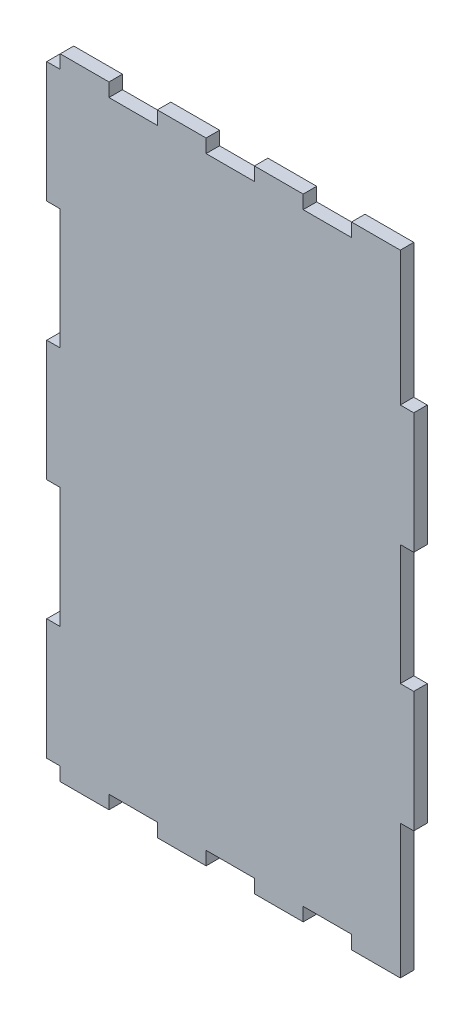
from build123d import *

# Parameters (mm, degrees)
SKETCH1_W           = 135.975
SKETCH1_H           = 241.325
SKETCH1_W_2         = 19.425
SKETCH1_H_2         = 5.4
SKETCH1_W_3         = 5.4
SKETCH1_H_3         = 48.265
BOSS_EXTRUDE1_DEPTH = 5.4
BOSS_EXTRUDE2_DEPTH = 5.4


with BuildPart() as part:
    # Sketch1 → Boss-Extrude1 (new body)
    with BuildSketch(Plane.XY):
        Rectangle(SKETCH1_W, SKETCH1_H)
        with Locations((58.275, 123.3625)):
            Rectangle(SKETCH1_W_2, SKETCH1_H_2)
        with Locations((19.425, 123.3625)):
            Rectangle(SKETCH1_W_2, SKETCH1_H_2)
        with Locations((-19.425, 123.3625)):
            Rectangle(SKETCH1_W_2, SKETCH1_H_2)
        with Locations((-70.6875, 96.53)):
            Rectangle(SKETCH1_W_3, SKETCH1_H_3)
        with Locations((-58.275, 123.3625)):
            Rectangle(SKETCH1_W_2, SKETCH1_H_2)
        with Locations((70.6875, 48.265)):
            Rectangle(SKETCH1_W_3, SKETCH1_H_3)
        with Locations((-70.6875, 0)):
            Rectangle(SKETCH1_W_3, SKETCH1_H_3)
        with Locations((70.6875, -48.265)):
            Rectangle(SKETCH1_W_3, SKETCH1_H_3)
        with Locations((-70.6875, -96.53)):
            Rectangle(SKETCH1_W_3, SKETCH1_H_3)
        with Locations((-58.275, -123.3625)):
            Rectangle(SKETCH1_W_2, SKETCH1_H_2)
        with Locations((-19.425, -123.3625)):
            Rectangle(SKETCH1_W_2, SKETCH1_H_2)
        with Locations((19.425, -123.3625)):
            Rectangle(SKETCH1_W_2, SKETCH1_H_2)
        with Locations((58.275, -123.3625)):
            Rectangle(SKETCH1_W_2, SKETCH1_H_2)
    extrude(amount=BOSS_EXTRUDE1_DEPTH)

    # Sketch2 → Boss-Extrude2 (add)
    with BuildSketch(Plane.XY.offset(5.4)):
        Polygon((-48.52186, -120.70314), (-29.17814, -120.70314), (-29.17814, -126.10314), (-9.67186, -126.10314), (-9.67186, -120.70314), (9.67186, -120.70314), (9.67186, -126.10314), (29.17814, -126.10314), (29.17814, -120.70314), (48.52186, -120.70314), (48.52186, -126.10314), (68.02814, -126.10314), (68.02814, -72.43814), (73.42814, -72.43814), (73.42814, -24.09186), (68.02814, -24.09186), (68.02814, 24.09186), (73.42814, 24.09186), (73.42814, 72.43814), (68.02814, 72.43814), (68.02814, 126.10314), (48.52186, 126.10314), (48.52186, 120.70314), (29.17814, 120.70314), (29.17814, 126.10314), (9.67186, 126.10314), (9.67186, 120.70314), (-9.67186, 120.70314), (-9.67186, 126.10314), (-29.17814, 126.10314), (-29.17814, 120.70314), (-48.52186, 120.70314), (-48.52186, 126.10314), (-68.02814, 126.10314), (-68.02814, 120.70314), (-73.42814, 120.70314), (-73.42814, 72.35686), (-68.02814, 72.35686), (-68.02814, 24.17314), (-73.42814, 24.17314), (-73.42814, -24.17314), (-68.02814, -24.17314), (-68.02814, -72.35686), (-73.42814, -72.35686), (-73.42814, -120.70314), (-68.02814, -120.70314), (-68.02814, -126.10314), (-48.52186, -126.10314), align=None)
    extrude(amount=-BOSS_EXTRUDE2_DEPTH)


solid = part.part
